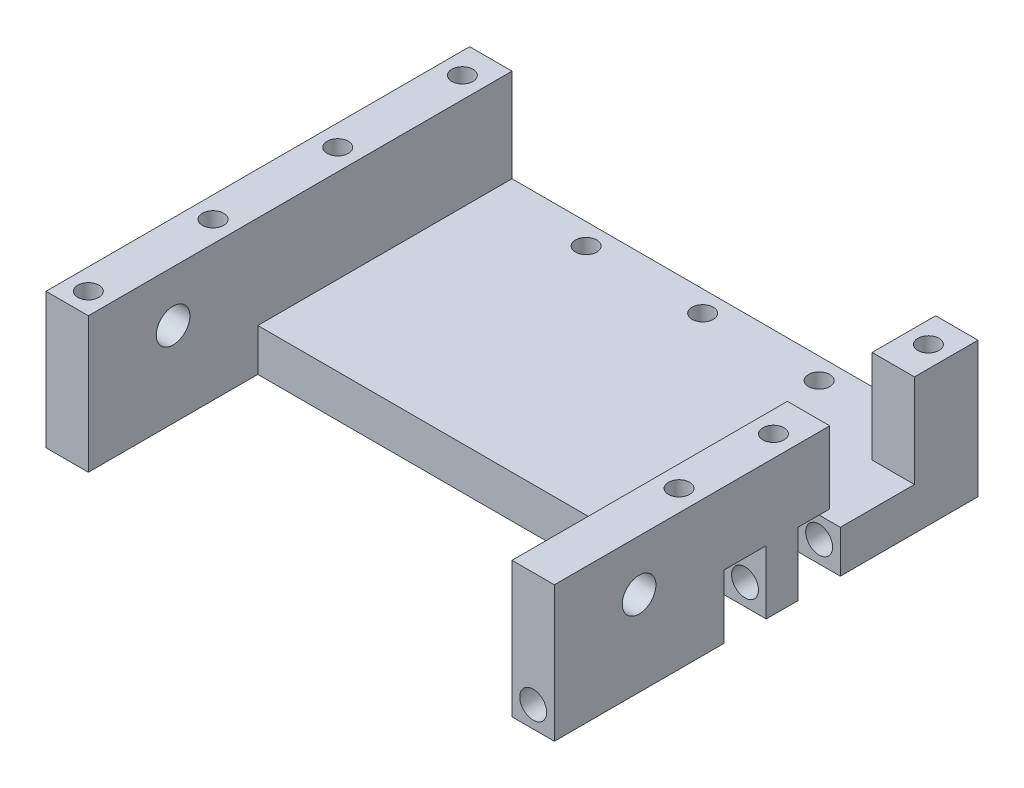
from build123d import *

# Parameters (mm, degrees)
BOSS_EXTRUDE3_DEPTH       = 50
SKETCH7_W                 = 100
SKETCH7_H                 = 40
CUT_EXTRUDE1_DEPTH        = 11
SKETCH8_R                 = 3.96875
CUT_EXTRUDE2_DEPTH        = 121
CUT_EXTRUDE3_REACH        = 122
SKETCH9_W                 = 20
SKETCH9_H                 = 22
SKETCH10_R                = 3.175
CUT_EXTRUDE4_DEPTH        = 80
SKETCH11_W                = 12.7
SKETCH11_H                = 10
CUT_EXTRUDE5_DEPTH        = 15
F_5_0MM_DOWEL_HOLE1_D     = 5
F_5_0MM_DOWEL_HOLE1_DEPTH = 25
F_5_0MM_DOWEL_HOLE1_TIP   = 1.502151548
SKETCH15_R                = 2.5
CUT_EXTRUDE6_DEPTH        = 15


with BuildPart() as part:
    # Sketch6 → Boss-Extrude3 (new body, symmetric)
    with BuildSketch(Plane.XY):
        Polygon((-60, 22), (-50, 22), (-50, 0), (50, 0), (50, 22), (60, 22), (60, -10), (-60, -10), align=None)
    extrude(amount=BOSS_EXTRUDE3_DEPTH, both=True)

    # Sketch7 → Cut-Extrude1 (cut, through all)
    with BuildSketch(Plane(origin=(0, 0, 0), x_dir=(1, 0, 0), z_dir=(0, 1, 0))):
        with Locations((0, -30)):
            Rectangle(SKETCH7_W, SKETCH7_H)
    extrude(amount=-CUT_EXTRUDE1_DEPTH, mode=Mode.SUBTRACT)

    # Sketch8 → Cut-Extrude2 (cut, through all)
    with BuildSketch(Plane(origin=(60, 0, 0), x_dir=(0, 0, -1), z_dir=(1, 0, 0))):
        with Locations((-30, 10)):
            Circle(SKETCH8_R)
    extrude(amount=-CUT_EXTRUDE2_DEPTH, mode=Mode.SUBTRACT)

    # Sketch9 → Cut-Extrude3 (cut, up to next)
    with BuildSketch(Plane(origin=(60, 0, 0), x_dir=(0, 0, -1), z_dir=(1, 0, 0)), mode=Mode.PRIVATE) as cut_extrude3_sk1:
        with Locations((25, 11)):
            Rectangle(SKETCH9_W, SKETCH9_H)
    cut_extrude3_tool1 = extrude(cut_extrude3_sk1.sketch, amount=-CUT_EXTRUDE3_REACH, mode=Mode.PRIVATE) & part.part
    add(cut_extrude3_tool1.solids().sort_by_distance((60, 11, -25))[0], mode=Mode.SUBTRACT)

    # Sketch10 → Cut-Extrude4 (cut)
    with BuildSketch(Plane.XY.offset(50)):
        with Locations((55, -5)):
            Circle(SKETCH10_R)
    extrude(amount=-CUT_EXTRUDE4_DEPTH, mode=Mode.SUBTRACT)

    # Sketch11 → Cut-Extrude5 (cut)
    with BuildSketch(Plane.XZ.offset(10)):
        with Locations((53.65, 5)):
            Rectangle(SKETCH11_W, SKETCH11_H)
        with Locations((53.65, -12.5)):
            Rectangle(SKETCH11_W, SKETCH11_H)
    extrude(amount=-CUT_EXTRUDE5_DEPTH, mode=Mode.SUBTRACT)

    # Ø5.0mm Dowel Hole1
    with Locations(Plane(origin=(-676.293536786, 32, -1303.282701689), x_dir=(1, 0, 0), z_dir=(0, 1, 0))):
        with Locations((731.293536786, -1318.853535022), (621.293536786, -1318.853535022), (621.293536786, -1348.282701689), (621.293536786, -1259.995201689), (731.293536786, -1259.995201689), (731.293536786, -1296.570201689), (621.293536786, -1289.424368355)):
            Hole(F_5_0MM_DOWEL_HOLE1_D / 2, depth=F_5_0MM_DOWEL_HOLE1_DEPTH)
            with Locations((0, 0, -(F_5_0MM_DOWEL_HOLE1_DEPTH + F_5_0MM_DOWEL_HOLE1_TIP / 2))):  # 118° drill point
                Cone(0, F_5_0MM_DOWEL_HOLE1_D / 2, F_5_0MM_DOWEL_HOLE1_TIP, mode=Mode.SUBTRACT)

    # Sketch15 → Cut-Extrude6 (cut)
    with BuildSketch(Plane.XZ.offset(10)):
        with Locations((-55, -45)):
            Circle(SKETCH15_R)
        with Locations((-27.5, -45)):
            Circle(SKETCH15_R)
        with Locations((0, -45)):
            Circle(SKETCH15_R)
        with Locations((27.5, -45)):
            Circle(SKETCH15_R)
        with Locations((55, -45)):
            Circle(SKETCH15_R)
    extrude(amount=-CUT_EXTRUDE6_DEPTH, mode=Mode.SUBTRACT)


solid = part.part
